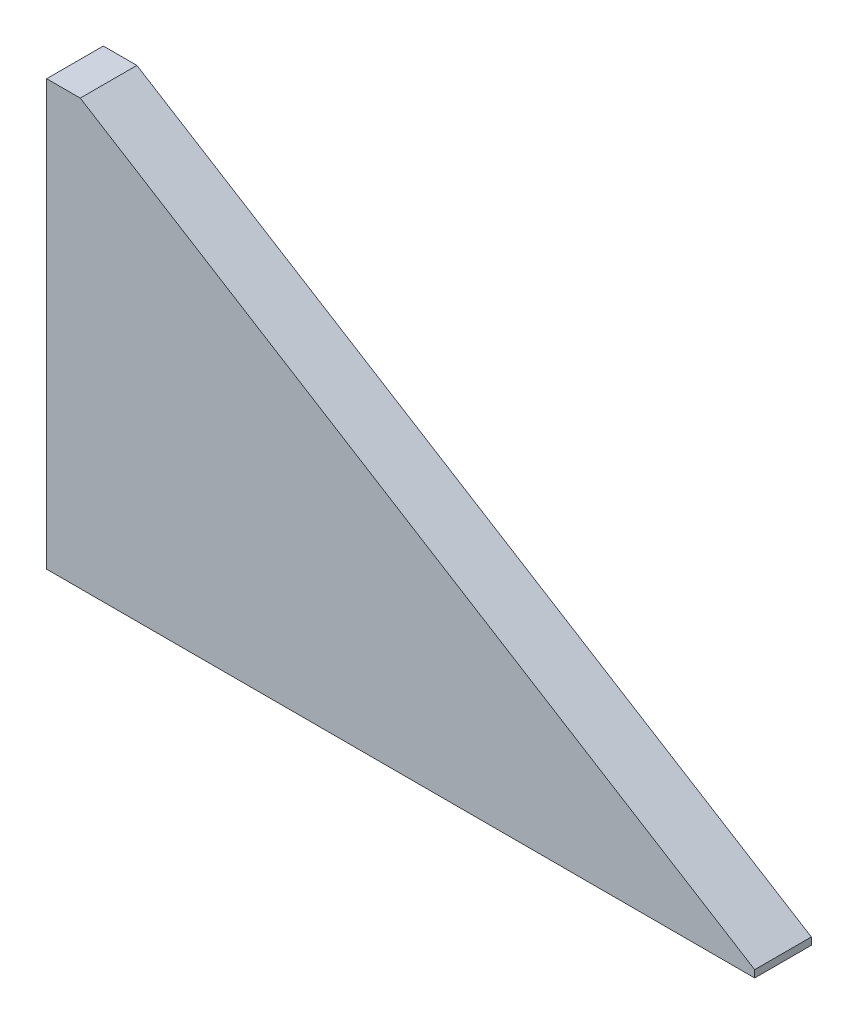
from build123d import *

# Parameters (mm, degrees)
ESQUISSE1_W             = 8
ESQUISSE1_H             = 60
BOSS_EXTRU_1_DEPTH      = 100
ENL_V_MAT_EXTRU_1_REACH = 10


with BuildPart() as part:
    # Esquisse1 → Boss.-Extru.1 (new body)
    with BuildSketch(Plane(origin=(0, 0, 0), x_dir=(0, 0, -1), z_dir=(1, 0, 0))):
        with Locations((-0.854369973, 29.104551848)):
            Rectangle(ESQUISSE1_W, ESQUISSE1_H)
    extrude(amount=-BOSS_EXTRU_1_DEPTH)

    # Esquisse2 → Enlèv. mat.-Extru.1 (cut, up to next)
    with BuildSketch(Plane.XY.offset(4.854369973), mode=Mode.PRIVATE) as enl_v_mat_extru_1_sk1:
        Polygon((-96, 59.563838708), (1.070476381, 60.732011114), (2.184337253, -1.224933167), align=None)
    enl_v_mat_extru_1_tool1 = extrude(enl_v_mat_extru_1_sk1.sketch, amount=-ENL_V_MAT_EXTRU_1_REACH, mode=Mode.PRIVATE) & part.part
    add(enl_v_mat_extru_1_tool1.solids().sort_by_distance((-30.915062, 39.690306, 4.85437))[0], mode=Mode.SUBTRACT)


solid = part.part
